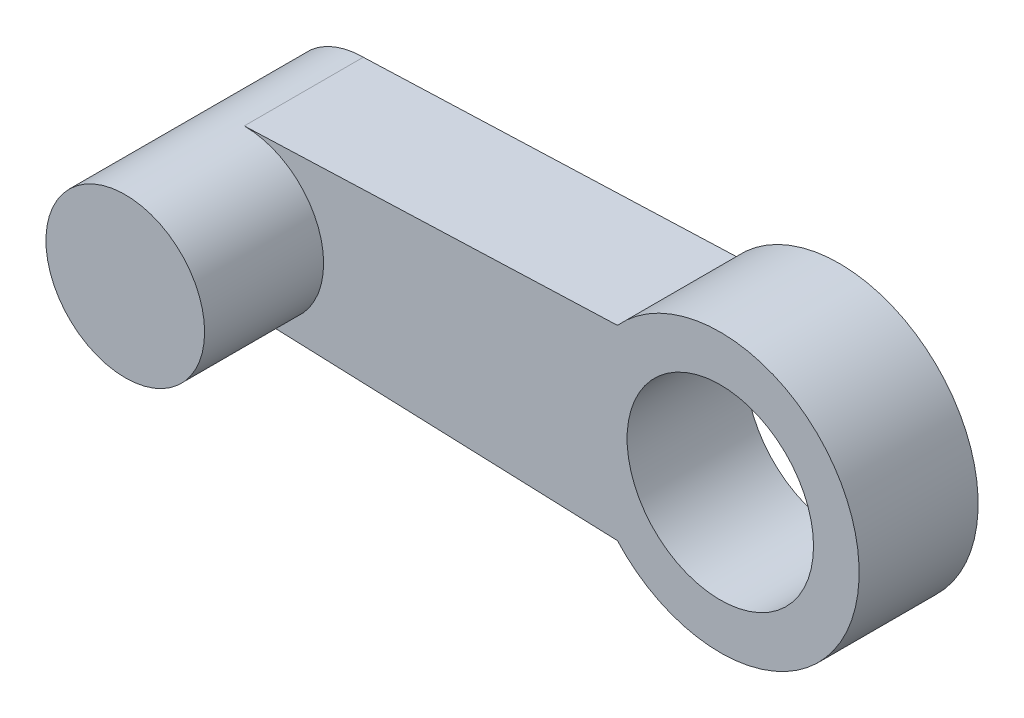
from build123d import *

# Parameters (mm, degrees)
SKETCH1_R           = 2.35
BOSS_EXTRUDE1_DEPTH = 3
SKETCH2_R           = 2
BOSS_EXTRUDE2_DEPTH = 3


with BuildPart() as part:
    # Sketch1 → Boss-Extrude1 (new body)
    with BuildSketch(Plane.XY):
        with BuildLine():
            Line((-1.533260445, 2.35), (-10.939517975, 2))
            ThreePointArc((-10.939517975, 2), (-12.939517975, 0), (-10.939517975, -2))
            Line((-10.939517975, -2), (-1.533260445, -2.35))
            ThreePointArc((-1.533260445, -2.35), (4.560482025, 0), (-1.533260445, 2.35))
        make_face()
        with Locations((1.060482025, 0)):
            Circle(SKETCH1_R, mode=Mode.SUBTRACT)
    extrude(amount=BOSS_EXTRUDE1_DEPTH)

    # Sketch2 → Boss-Extrude2 (add)
    with BuildSketch(Plane.XY.offset(3)):
        with Locations((-10.939517975, 0)):
            Circle(SKETCH2_R)
    extrude(amount=BOSS_EXTRUDE2_DEPTH)


solid = part.part
